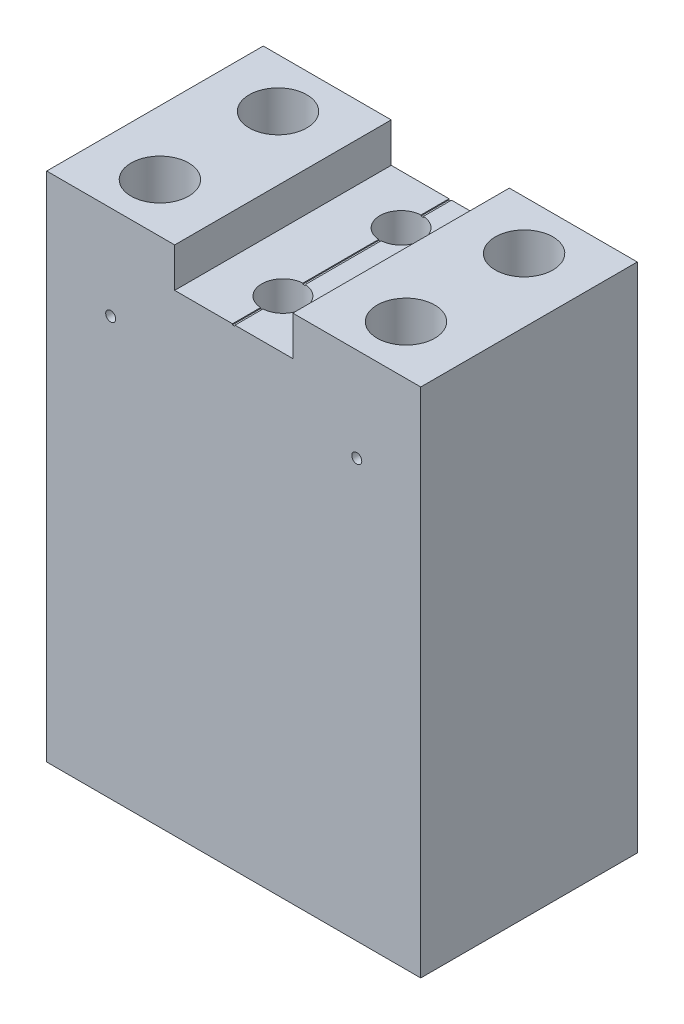
from build123d import *

# Parameters (mm, degrees)
SKETCH1_W             = 38
SKETCH1_H             = 52
EXTRUDE1_DEPTH        = 22
SKETCH2_R             = 2.925
CUT_EXTRUDE1_DEPTH    = 12.7
SKETCH5_W             = 12
SKETCH5_H             = 22
CUT_EXTRUDE4_DEPTH    = 4
F_8_CLEARANCE_HOLE1_D = 4.3053
CUT_EXTRUDE5_REACH    = 61.573
SKETCH8_R             = 0.508
SKETCH9_W             = 0.25
SKETCH9_H             = 22
CUT_EXTRUDE6_DEPTH    = 0.1


with BuildPart() as part:
    # Sketch1 → Extrude1 (new body)
    with BuildSketch(Plane.XY):
        with Locations((0, 26)):
            Rectangle(SKETCH1_W, SKETCH1_H)
    extrude(amount=EXTRUDE1_DEPTH)

    # Sketch2 → Cut-Extrude1 (cut)
    with BuildSketch(Plane(origin=(0, 52, 0), x_dir=(-1, 0, 0), z_dir=(0, 1, 0))):
        with Locations(Location((12.5, 5, 0), (0, 0, 90))):
            Circle(SKETCH2_R)
        with Locations(Location((12.5, 17, 0), (0, 0, 270))):
            Circle(SKETCH2_R)
        with Locations(Location((-12.5, 17, 0), (0, 0, 90))):
            Circle(SKETCH2_R)
        with Locations(Location((-12.5, 5, 0), (0, 0, 270))):
            Circle(SKETCH2_R)
    extrude(amount=-CUT_EXTRUDE1_DEPTH, mode=Mode.SUBTRACT)

    # Sketch5 → Cut-Extrude4 (cut)
    with BuildSketch(Plane(origin=(0, 52, 0), x_dir=(-1, 0, 0), z_dir=(0, 1, 0))):
        with Locations((0, 11)):
            Rectangle(SKETCH5_W, SKETCH5_H)
    extrude(amount=-CUT_EXTRUDE4_DEPTH, mode=Mode.SUBTRACT)

    # #8 Clearance Hole1 (through all)
    with Locations(Plane(origin=(0, 48, 0), x_dir=(-1, 0, 0), z_dir=(0, 1, 0))):
        with Locations((0, 17), (0, 5)):
            Hole(F_8_CLEARANCE_HOLE1_D / 2)

    # Sketch8 → Cut-Extrude5 (cut, up to next)
    with BuildSketch(Plane.XY.offset(22), mode=Mode.PRIVATE) as cut_extrude5_sk1:
        with Locations((-12.5, 42.475)):
            Circle(SKETCH8_R)
    cut_extrude5_tool1 = extrude(cut_extrude5_sk1.sketch, amount=-CUT_EXTRUDE5_REACH, mode=Mode.PRIVATE) & part.part
    # Sketch8 → Cut-Extrude5 (cut, up to next)
    with BuildSketch(Plane.XY.offset(22), mode=Mode.PRIVATE) as cut_extrude5_sk2:
        with Locations((12.5, 42.475)):
            Circle(SKETCH8_R)
    cut_extrude5_tool2 = extrude(cut_extrude5_sk2.sketch, amount=-CUT_EXTRUDE5_REACH, mode=Mode.PRIVATE) & part.part
    cut_extrude5_1 = cut_extrude5_tool1.solids().sort_by_distance((-12.5, 42.475, 22))[0]
    add(cut_extrude5_1, mode=Mode.SUBTRACT)
    cut_extrude5_2 = cut_extrude5_tool2.solids().sort_by_distance((12.5, 42.475, 22))[0]
    add(cut_extrude5_2, mode=Mode.SUBTRACT)
    cut_extrude5 = cut_extrude5_1 + cut_extrude5_2  # Cut-Extrude5 as one shape, for the pattern or mirror that repeats it

    # Mirror1: Cut-Extrude5 mirrored; each copy of Cut-Extrude5 runs up to whatever stops it at its own place
    mirror1_before = part.part  # the part as the pattern finds it: every copy runs up to it
    mirror1_cut_extrude5_long1 = extrude(cut_extrude5_sk1.sketch, amount=-CUT_EXTRUDE5_REACH, mode=Mode.PRIVATE)
    mirror1_cut_extrude5_long2 = extrude(cut_extrude5_sk2.sketch, amount=-CUT_EXTRUDE5_REACH, mode=Mode.PRIVATE)
    mirror1_cut_extrude5_tool = mirror1_cut_extrude5_long1.mirror(Plane.XY) & mirror1_before
    add(mirror1_cut_extrude5_tool.solids().sort_by_distance((-12.5, 42.475, -22))[0], mode=Mode.SUBTRACT)
    mirror1_cut_extrude5_tool = mirror1_cut_extrude5_long2.mirror(Plane.XY) & mirror1_before
    add(mirror1_cut_extrude5_tool.solids().sort_by_distance((12.5, 42.475, -22))[0], mode=Mode.SUBTRACT)

    # Sketch9 → Cut-Extrude6 (cut)
    with BuildSketch(Plane(origin=(0, 48, 0), x_dir=(-1, 0, 0), z_dir=(0, 1, 0))):
        with Locations((0, 11)):
            Rectangle(SKETCH9_W, SKETCH9_H)
    extrude(amount=-CUT_EXTRUDE6_DEPTH, mode=Mode.SUBTRACT)


solid = part.part
